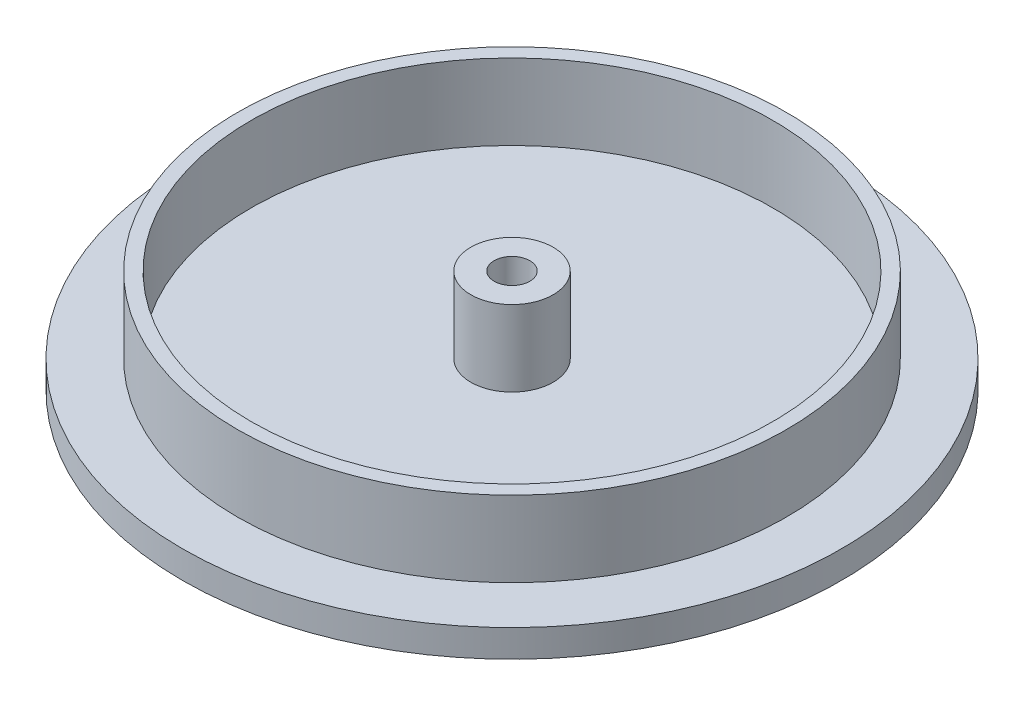
from build123d import *

# Parameters (mm, degrees)
SKETCH1_R           = 60
BOSS_EXTRUDE1_DEPTH = 5
SKETCH2_R           = 50
BOSS_EXTRUDE2_DEPTH = 13.8
SKETCH3_R           = 47.5
CUT_EXTRUDE1_DEPTH  = 13.8
SKETCH4_R           = 7.5
BOSS_EXTRUDE3_DEPTH = 13.8
SKETCH6_R           = 3.25
CUT_EXTRUDE2_DEPTH  = 35


with BuildPart() as part:
    # Sketch1 → Boss-Extrude1 (new body)
    with BuildSketch(Plane(origin=(0, 0, 0), x_dir=(1, 0, 0), z_dir=(0, 1, 0))):
        Circle(SKETCH1_R)
    extrude(amount=BOSS_EXTRUDE1_DEPTH)

    # Sketch2 → Boss-Extrude2 (add)
    with BuildSketch(Plane(origin=(0, 5, 0), x_dir=(1, 0, 0), z_dir=(0, 1, 0))):
        Circle(SKETCH2_R)
    extrude(amount=BOSS_EXTRUDE2_DEPTH)

    # Sketch3 → Cut-Extrude1 (cut)
    with BuildSketch(Plane(origin=(0, 18.8, 0), x_dir=(1, 0, 0), z_dir=(0, 1, 0))):
        Circle(SKETCH3_R)
    extrude(amount=-CUT_EXTRUDE1_DEPTH, mode=Mode.SUBTRACT)

    # Sketch4 → Boss-Extrude3 (add)
    with BuildSketch(Plane(origin=(0, 5, 0), x_dir=(1, 0, 0), z_dir=(0, 1, 0))):
        Circle(SKETCH4_R)
    extrude(amount=BOSS_EXTRUDE3_DEPTH)

    # Sketch6 → Cut-Extrude2 (cut)
    with BuildSketch(Plane(origin=(0, 18.8, 0), x_dir=(1, 0, 0), z_dir=(0, 1, 0))):
        Circle(SKETCH6_R)
    extrude(amount=-CUT_EXTRUDE2_DEPTH, mode=Mode.SUBTRACT)


solid = part.part
